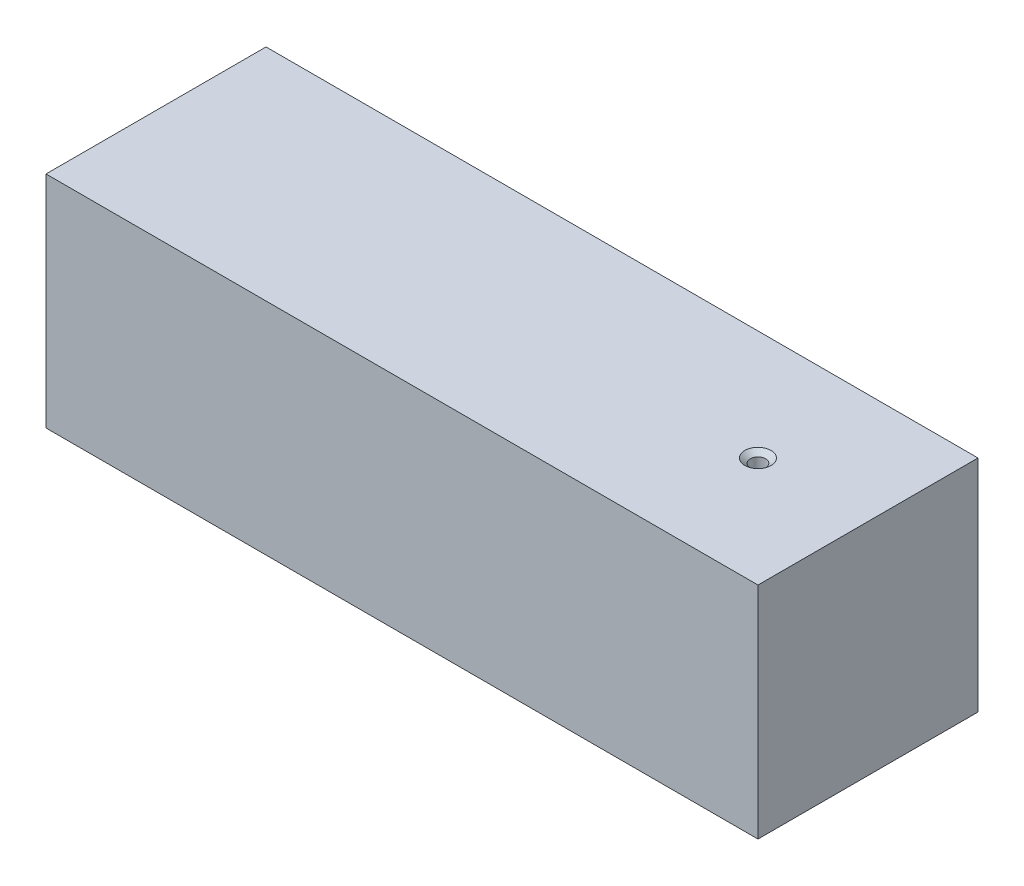
from build123d import *

# Parameters (mm, degrees)
SKETCH1_W                                         = 82.19
SKETCH1_H                                         = 25.4
BOSS_EXTRUDE1_DEPTH                               = 25.4
CSK_FOR_0_FLAT_HEAD_MACHINE_SCREW_100_D           = 1.778
CSK_FOR_0_FLAT_HEAD_MACHINE_SCREW_100_CSINK_D     = 3.0226
CSK_FOR_0_FLAT_HEAD_MACHINE_SCREW_100_CSINK_ANGLE = 100
F_0_80_TAPPED_HOLE1_D                             = 1.19126
F_0_80_TAPPED_HOLE1_DEPTH                         = 20
F_0_80_TAPPED_HOLE1_CSINK_D                       = 3.0226
F_0_80_TAPPED_HOLE1_CSINK_ANGLE                   = 100
F_0_80_TAPPED_HOLE1_TIP                           = 0.357890611


with BuildPart() as part:
    # Sketch1 → Boss-Extrude1 (new body)
    with BuildSketch(Plane(origin=(0, 0, 0), x_dir=(1, 0, 0), z_dir=(0, 1, 0))):
        Rectangle(SKETCH1_W, SKETCH1_H)
    extrude(amount=BOSS_EXTRUDE1_DEPTH)

    # CSK for #0 Flat Head Machine Screw (100)1 (through all)
    with Locations(Plane(origin=(0, 25.4, 0), x_dir=(1, 0, 0), z_dir=(0, 1, 0))):
        with Locations((28.395, 0)):
            CounterSinkHole(CSK_FOR_0_FLAT_HEAD_MACHINE_SCREW_100_D / 2, CSK_FOR_0_FLAT_HEAD_MACHINE_SCREW_100_CSINK_D / 2, counter_sink_angle=CSK_FOR_0_FLAT_HEAD_MACHINE_SCREW_100_CSINK_ANGLE)

    # #0-80 Tapped Hole1
    with Locations(Plane.ZY.offset(41.095)):
        with Locations((0, 12.7)):
            CounterSinkHole(F_0_80_TAPPED_HOLE1_D / 2, F_0_80_TAPPED_HOLE1_CSINK_D / 2, depth=F_0_80_TAPPED_HOLE1_DEPTH, counter_sink_angle=F_0_80_TAPPED_HOLE1_CSINK_ANGLE)
            with Locations((0, 0, -(F_0_80_TAPPED_HOLE1_DEPTH + F_0_80_TAPPED_HOLE1_TIP / 2))):  # 118° drill point
                Cone(0, F_0_80_TAPPED_HOLE1_D / 2, F_0_80_TAPPED_HOLE1_TIP, mode=Mode.SUBTRACT)


solid = part.part
